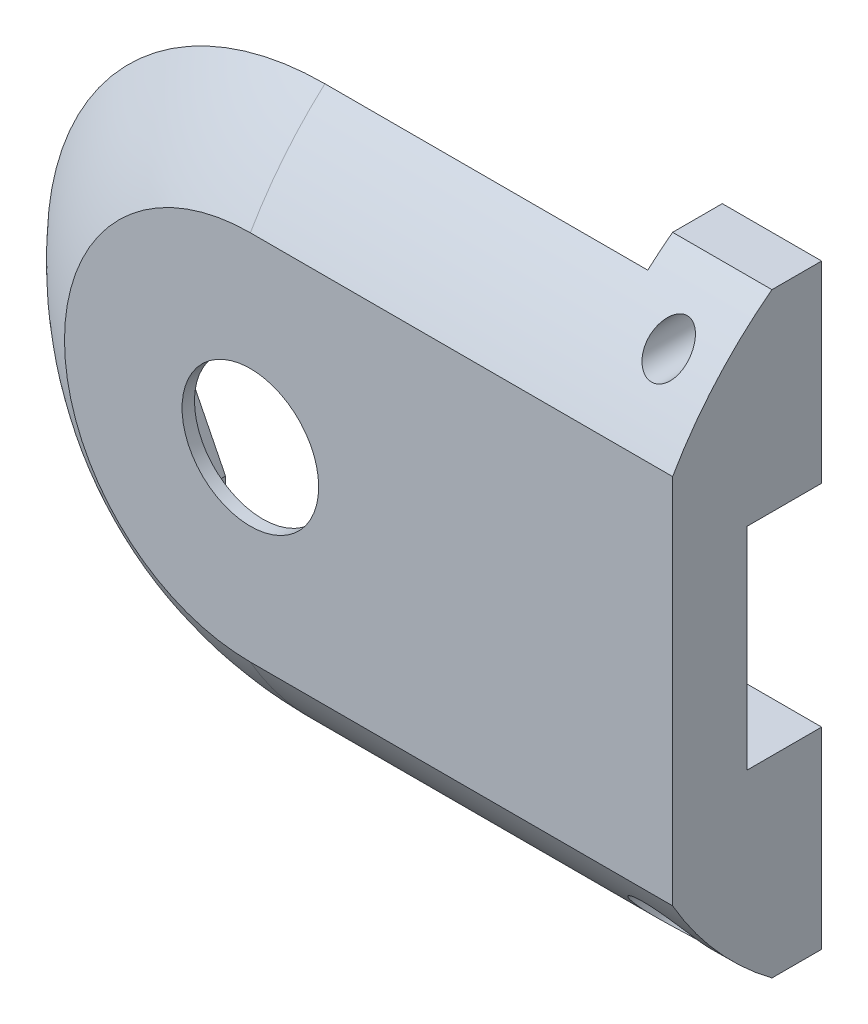
from build123d import *

# Parameters (mm, degrees)
SKETCH1_R           = 2.75
BOSS_EXTRUDE1_DEPTH = 6
BODY_START          = -3
SKETCH2_R           = 2.75
BODY_HOLE_DEPTH     = 3
POT_START           = -3
POT_INSERT_DEPTH    = 2.5
CUT_EXTRUDE2_DEPTH  = 23.226110771
CUT_REVOLVE1_ANGLE  = 180
SKETCH7_R           = 0.8
SCREW_HOLES_DEPTH   = 22.656407828
SKETCH9_R           = 1.25
SCREW_HEADS_DEPTH   = 4


with BuildPart() as part:
    # Sketch1 → Boss-Extrude1 (new body)
    with BuildSketch(Plane.XY):
        with BuildLine():
            Line((17, -12), (17, 12))
            Line((17, 12), (5, 12))
            ThreePointArc((5, 12), (-13, 0), (5, -12))
            Line((5, -12), (17, -12))
        make_face()
        Circle(SKETCH1_R, mode=Mode.SUBTRACT)
    extrude(amount=-BOSS_EXTRUDE1_DEPTH)

    # Sketch2 → Body Hole (cut)
    with BuildSketch(Plane.XY.offset(BODY_START)):
        with BuildLine():
            ThreePointArc((5, 12), (-13, 0), (5, -12))
            Line((5, -12), (13, -12))
            Line((13, -12), (13, -4.25))
            Line((13, -4.25), (17, -4.25))
            Line((17, -4.25), (17, 4.25))
            Line((17, 4.25), (13, 4.25))
            Line((13, 4.25), (13, 12))
            Line((13, 12), (5, 12))
        make_face()
        Circle(SKETCH2_R, mode=Mode.SUBTRACT)
    extrude(amount=-BODY_HOLE_DEPTH, mode=Mode.SUBTRACT)

    # Sketch8 → Pot Insert (cut)
    with BuildSketch(Plane(origin=(28.28760271, 0, 0), x_dir=(1, 0, 0), z_dir=(0, 0, 1)).offset(POT_START)):
        Polygon((-35.287602709, 0), (-35.287602709, -1.5), (-33.787602709, -1.5), (-32.287602709, -4.5), (-32.287602709, -5.5), (-28.287602709, -5.5), (-24.037602709, -5.5), (-24.037602709, -4.5), (-18.787602709, -4.5), (-18.787602709, 0), (-18.787602709, 4.5), (-24.037602709, 4.5), (-24.037602709, 5.5), (-28.287602709, 5.5), (-32.287602709, 5.5), (-32.287602709, 4.5), (-33.787602709, 1.5), (-35.287602709, 1.5), align=None)
    extrude(amount=POT_INSERT_DEPTH, mode=Mode.SUBTRACT)

    # Sketch3 → Cut-Extrude2 (cut, through all)
    with BuildSketch(Plane(origin=(0, 0, 0), x_dir=(0, 0, -1), z_dir=(1, 0, 0))):
        with BuildLine():
            ThreePointArc((-2, 0), (2.393398282, 10.606601718), (13, 15))
            Line((13, 15), (-2, 15))
            Line((-2, 15), (-2, 0))
        make_face()
        with BuildLine():
            ThreePointArc((13, -15), (2.393398282, -10.606601718), (-2, 0))
            Line((-2, 0), (-2, -15))
            Line((-2, -15), (13, -15))
        make_face()
    extrude(amount=CUT_EXTRUDE2_DEPTH, mode=Mode.SUBTRACT)

    # Sketch6 → Cut-Revolve1 (revolve, cut)
    with BuildSketch(Plane(origin=(0, 0, 0), x_dir=(0, 0, -1), z_dir=(1, 0, 0))):
        with BuildLine():
            ThreePointArc((-1, 5.385164807), (4.508164866, 12.36481848), (13, 15))
            Line((13, 15), (-2, 15))
            Line((-2, 15), (-2, 5.385164807))
            Line((-2, 5.385164807), (-1, 5.385164807))
        make_face()
    revolve(axis=Axis((0, 0, 0), (0, 0, 1)), revolution_arc=CUT_REVOLVE1_ANGLE, mode=Mode.SUBTRACT)

    # Sketch7 → Screw Holes (cut, through all)
    with BuildSketch(Plane.XY):
        with Locations((15, 10)):
            Circle(SKETCH7_R)
        with Locations((15, -10)):
            Circle(SKETCH7_R)
    extrude(amount=-SCREW_HOLES_DEPTH, mode=Mode.SUBTRACT)

    # Sketch9 → Screw Heads (cut)
    with BuildSketch(Plane.XY):
        with Locations((15, -10)):
            Circle(SKETCH9_R)
    extrude(amount=-SCREW_HEADS_DEPTH, mode=Mode.SUBTRACT)


solid = part.part
